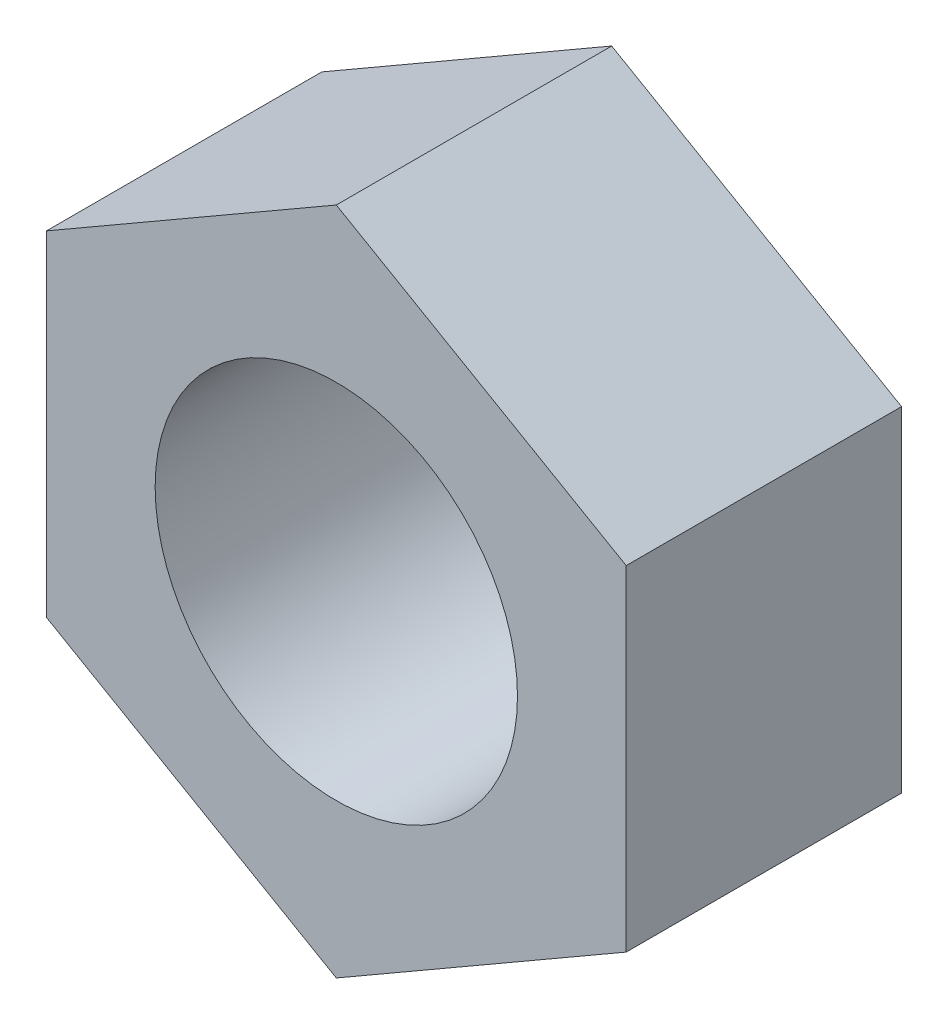
from build123d import *

# Parameters (mm, degrees)
SKETCH1_R           = 2.5
BOSS_EXTRUDE1_DEPTH = 3.8


with BuildPart() as part:
    # Sketch1 → Boss-Extrude1 (new body)
    with BuildSketch(Plane.XY):
        Polygon((0, 4.618802154), (-4, 2.309401077), (-4, -2.309401077), (0, -4.618802154), (4, -2.309401077), (4, 2.309401077), align=None)
        Circle(SKETCH1_R, mode=Mode.SUBTRACT)
    extrude(amount=BOSS_EXTRUDE1_DEPTH)


solid = part.part
